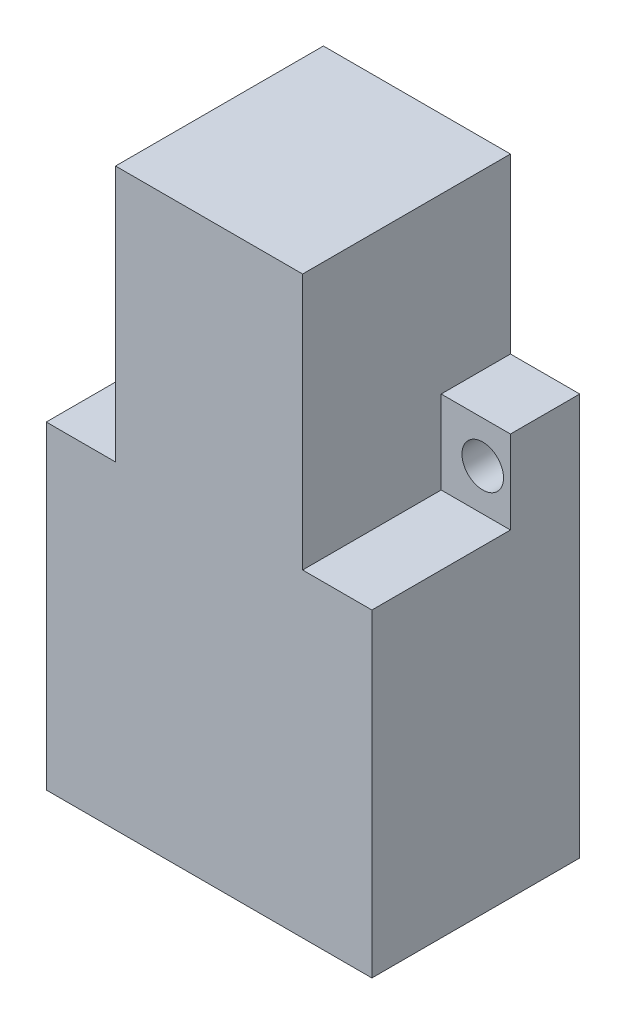
from build123d import *

# Parameters (mm, degrees)
SKETCH_1_W          = 23.5
SKETCH_1_H          = 41.5
EXTRUDE_1_DEPTH     = 15
SKETCH_2_W          = 5
SKETCH_2_H          = 18.5
CUT_EXTRUDE_1_DEPTH = 10
SKETCH_3_W          = 5
SKETCH_3_H          = 12.5
CUT_EXTRUDE_2_DEPTH = 6
SKETCH_4_R          = 1.5
CUT_EXTRUDE_3_DEPTH = 6


with BuildPart() as part:
    # 草图1 → 凸台-拉伸1 (new body)
    with BuildSketch(Plane.XY):
        Rectangle(SKETCH_1_W, SKETCH_1_H)
    extrude(amount=EXTRUDE_1_DEPTH)

    # 草图2 → 切除-拉伸1 (cut)
    with BuildSketch(Plane.XY.offset(15)):
        with Locations((-9.25, 11.5)):
            Rectangle(SKETCH_2_W, SKETCH_2_H)
        with Locations((9.25, 11.5)):
            Rectangle(SKETCH_2_W, SKETCH_2_H)
    extrude(amount=-CUT_EXTRUDE_1_DEPTH, mode=Mode.SUBTRACT)

    # 草图3 → 切除-拉伸2 (cut, through all)
    with BuildSketch(Plane.XY.offset(5)):
        with Locations((-9.25, 14.5)):
            Rectangle(SKETCH_3_W, SKETCH_3_H)
        with Locations((9.25, 14.5)):
            Rectangle(SKETCH_3_W, SKETCH_3_H)
    extrude(amount=-CUT_EXTRUDE_2_DEPTH, mode=Mode.SUBTRACT)

    # 草图4 → 切除-拉伸3 (cut, through all)
    with BuildSketch(Plane.XY.offset(5)):
        with Locations((-9.75, 5.25)):
            Circle(SKETCH_4_R)
        with Locations((9.75, 5.25)):
            Circle(SKETCH_4_R)
    extrude(amount=-CUT_EXTRUDE_3_DEPTH, mode=Mode.SUBTRACT)


solid = part.part
